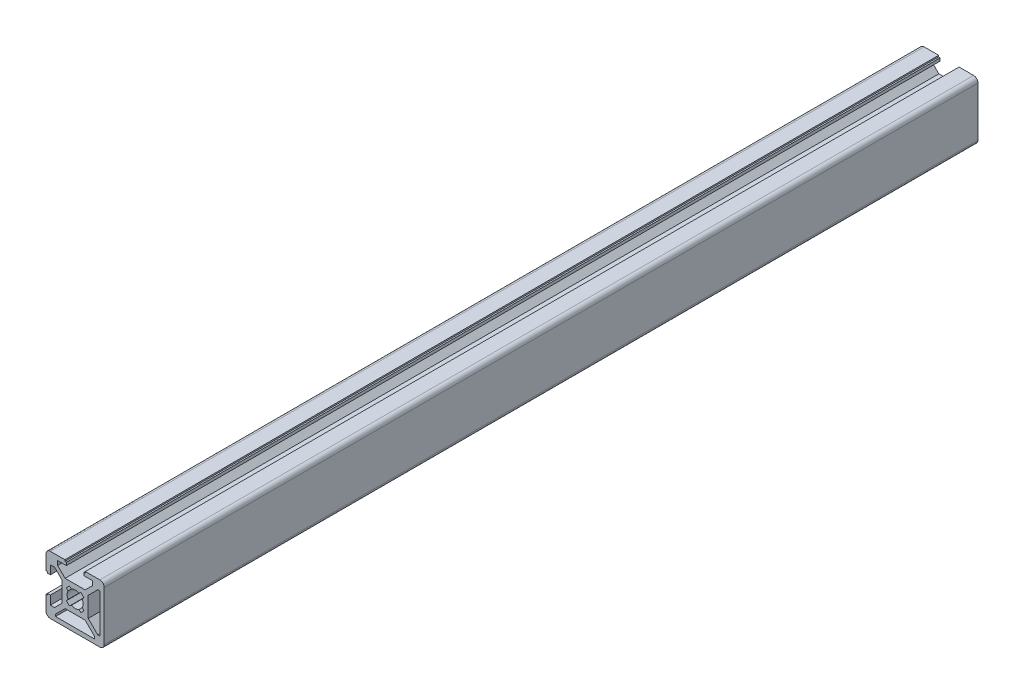
from build123d import *

# Parameters (mm, degrees)
BOSS_EXTRUDE1_DEPTH = 1000
CUT_EXTRUDE1_DEPTH  = 700


with BuildPart() as part:
    # Sketch1 → Boss-Extrude1 (new body)
    with BuildSketch(Plane.XY):
        with BuildLine():
            Line((6, 7.06066017), (3.43933983, 4.5))
            Line((3.43933983, 4.5), (-3.43933983, 4.5))
            Line((-3.43933983, 4.5), (-6, 7.06066017))
            Line((-6, 7.06066017), (-6, 8.5))
            Line((-6, 8.5), (-3, 8.5))
            Line((-3, 8.5), (-3, 9.5))
            Line((-3, 9.5), (-3.5, 9.5))
            Line((-3.5, 9.5), (-3.5, 10))
            Line((-3.5, 10), (-8.5, 10))
            ThreePointArc((-8.5, 10), (-9.56066017, 9.56066017), (-10, 8.5))
            Line((-10, 8.5), (-10, 3.5))
            Line((-10, 3.5), (-9.5, 3.5))
            Line((-9.5, 3.5), (-9.5, 3))
            Line((-9.5, 3), (-8.5, 3))
            Line((-8.5, 3), (-8.5, 6))
            Line((-8.5, 6), (-7.06066017, 6))
            Line((-7.06066017, 6), (-4.5, 3.43933983))
            Line((-4.5, 3.43933983), (-4.5, -3.43933983))
            Line((-4.5, -3.43933983), (-7.06066017, -6))
            Line((-7.06066017, -6), (-8.5, -6))
            Line((-8.5, -6), (-8.5, -3))
            Line((-8.5, -3), (-9.5, -3))
            Line((-9.5, -3), (-9.5, -3.5))
            Line((-9.5, -3.5), (-10, -3.5))
            Line((-10, -3.5), (-10, -8.5))
            ThreePointArc((-10, -8.5), (-9.56066017, -9.56066017), (-8.5, -10))
            Line((-8.5, -10), (8.5, -10))
            ThreePointArc((8.5, -10), (9.56066017, -9.56066017), (10, -8.5))
            Line((10, -8.5), (10, 8.5))
            ThreePointArc((10, 8.5), (9.56066017, 9.56066017), (8.5, 10))
            Line((8.5, 10), (3.5, 10))
            Line((3.5, 10), (3.5, 9.5))
            Line((3.5, 9.5), (3, 9.5))
            Line((3, 9.5), (3, 8.5))
            Line((3, 8.5), (6, 8.5))
            Line((6, 8.5), (6, 7.06066017))
        make_face()
        Polygon((4.5, -3.43933983), (4.5, 3.43933983), (7.79289322, 6.73223305), (8.5, 6.73223305), (8.5, -6.73223305), (7.79289322, -6.73223305), align=None, mode=Mode.SUBTRACT)
        with BuildLine():
            Line((-2.43563636, 1.27678327), (-3.0001742, 1.94957327))
            Line((-3.0001742, 1.94957327), (-1.94957327, 3.0001742))
            Line((-1.94957327, 3.0001742), (-1.27678327, 2.43563636))
            ThreePointArc((-1.27678327, 2.43563636), (0, 2.75), (1.27678327, 2.43563636))
            Line((1.27678327, 2.43563636), (1.94957327, 3.0001742))
            Line((1.94957327, 3.0001742), (3.0001742, 1.94957327))
            Line((3.0001742, 1.94957327), (2.43563636, 1.27678327))
            ThreePointArc((2.43563636, 1.27678327), (2.75, 0), (2.43563636, -1.27678327))
            Line((2.43563636, -1.27678327), (3.0001742, -1.94957327))
            Line((3.0001742, -1.94957327), (1.94957327, -3.0001742))
            Line((1.94957327, -3.0001742), (1.27678327, -2.43563636))
            ThreePointArc((1.27678327, -2.43563636), (0, -2.75), (-1.27678327, -2.43563636))
            Line((-1.27678327, -2.43563636), (-1.94957327, -3.0001742))
            Line((-1.94957327, -3.0001742), (-3.0001742, -1.94957327))
            Line((-3.0001742, -1.94957327), (-2.43563636, -1.27678327))
            ThreePointArc((-2.43563636, -1.27678327), (-2.75, 0), (-2.43563636, 1.27678327))
        make_face(mode=Mode.SUBTRACT)
        Polygon((3.43933983, -4.5), (6.73223305, -7.79289322), (6.73223305, -8.5), (-6.73223305, -8.5), (-6.73223305, -7.79289322), (-3.43933983, -4.5), align=None, mode=Mode.SUBTRACT)
    extrude(amount=BOSS_EXTRUDE1_DEPTH)

    # Sketch3 → Cut-Extrude1 (cut)
    with BuildSketch(Plane.XY.offset(1000)):
        with BuildLine():
            Line((6, 8.5), (6, 7.06066017))
            Line((6, 7.06066017), (3.43933983, 4.5))
            Line((3.43933983, 4.5), (-3.43933983, 4.5))
            Line((-3.43933983, 4.5), (-6, 7.06066017))
            Line((-6, 7.06066017), (-6, 8.5))
            Line((-6, 8.5), (-3, 8.5))
            Line((-3, 8.5), (-3, 9.5))
            Line((-3, 9.5), (-3.5, 9.5))
            Line((-3.5, 9.5), (-3.5, 10))
            Line((-3.5, 10), (-8.5, 10))
            ThreePointArc((-8.5, 10), (-9.56066017, 9.56066017), (-10, 8.5))
            Line((-10, 8.5), (-10, 3.5))
            Line((-10, 3.5), (-9.5, 3.5))
            Line((-9.5, 3.5), (-9.5, 3))
            Line((-9.5, 3), (-8.5, 3))
            Line((-8.5, 3), (-8.5, 6))
            Line((-8.5, 6), (-7.06066017, 6))
            Line((-7.06066017, 6), (-4.5, 3.43933983))
            Line((-4.5, 3.43933983), (-4.5, -3.43933983))
            Line((-4.5, -3.43933983), (-7.06066017, -6))
            Line((-7.06066017, -6), (-8.5, -6))
            Line((-8.5, -6), (-8.5, -3))
            Line((-8.5, -3), (-9.5, -3))
            Line((-9.5, -3), (-9.5, -3.5))
            Line((-9.5, -3.5), (-10, -3.5))
            Line((-10, -3.5), (-10, -8.5))
            ThreePointArc((-10, -8.5), (-9.56066017, -9.56066017), (-8.5, -10))
            Line((-8.5, -10), (8.5, -10))
            ThreePointArc((8.5, -10), (9.56066017, -9.56066017), (10, -8.5))
            Line((10, -8.5), (10, 8.5))
            ThreePointArc((10, 8.5), (9.56066017, 9.56066017), (8.5, 10))
            Line((8.5, 10), (3.5, 10))
            Line((3.5, 10), (3.5, 9.5))
            Line((3.5, 9.5), (3, 9.5))
            Line((3, 9.5), (3, 8.5))
            Line((3, 8.5), (6, 8.5))
        make_face()
    extrude(amount=-CUT_EXTRUDE1_DEPTH, mode=Mode.SUBTRACT)


solid = part.part
